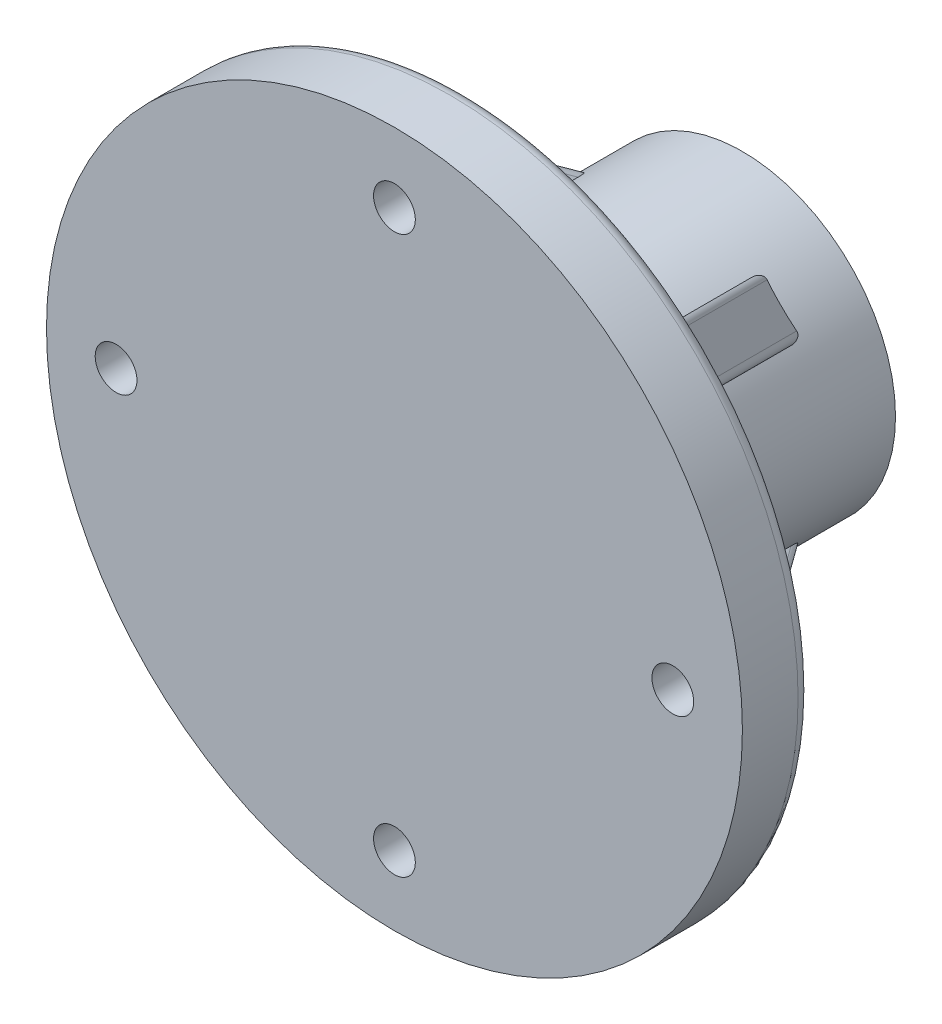
from build123d import *

# Parameters (mm, degrees)
SKETCH1_R           = 11
BOSS_EXTRUDE1_DEPTH = 20
SKETCH5_R           = 25
BOSS_EXTRUDE2_DEPTH = 5
CUT_EXTRUDE2_REACH  = 42.62
SKETCH6_R           = 1.5
FILLET2_R           = 5
RIB10_REACH         = 45.301
SKETCH12_WALL_W     = 107.81191309
SKETCH12_WALL_H     = 4
CIRPATTERN1_COUNT   = 4
FILLET3_R           = 1
FILLET4_R           = 0.5
SKETCH13_R          = 3
CUT_EXTRUDE3_DEPTH  = 1
SKETCH14_R          = 1.5
CUT_EXTRUDE4_DEPTH  = 12


with BuildPart() as part:
    # Sketch1 → Boss-Extrude1 (new body)
    with BuildSketch(Plane.XY):
        Circle(SKETCH1_R)
    extrude(amount=BOSS_EXTRUDE1_DEPTH)

    # Sketch5 → Boss-Extrude2 (add)
    with BuildSketch(Plane.XY.offset(20)):
        Circle(SKETCH5_R)
    extrude(amount=BOSS_EXTRUDE2_DEPTH)

    # Sketch6 → Cut-Extrude2 (cut, up to next)
    with BuildSketch(Plane(origin=(0, 0, 20), x_dir=(-1, 0, 0), z_dir=(0, 0, -1)), mode=Mode.PRIVATE) as cut_extrude2_sk1:
        with Locations((0, 20)):
            Circle(SKETCH6_R)
    cut_extrude2_tool1 = extrude(cut_extrude2_sk1.sketch, amount=-CUT_EXTRUDE2_REACH, mode=Mode.PRIVATE) & part.part
    # Sketch6 → Cut-Extrude2 (cut, up to next)
    with BuildSketch(Plane(origin=(0, 0, 20), x_dir=(-1, 0, 0), z_dir=(0, 0, -1)), mode=Mode.PRIVATE) as cut_extrude2_sk2:
        with Locations((0, -20)):
            Circle(SKETCH6_R)
    cut_extrude2_tool2 = extrude(cut_extrude2_sk2.sketch, amount=-CUT_EXTRUDE2_REACH, mode=Mode.PRIVATE) & part.part
    # Sketch6 → Cut-Extrude2 (cut, up to next)
    with BuildSketch(Plane(origin=(0, 0, 20), x_dir=(-1, 0, 0), z_dir=(0, 0, -1)), mode=Mode.PRIVATE) as cut_extrude2_sk3:
        with Locations((-20, 0)):
            Circle(SKETCH6_R)
    cut_extrude2_tool3 = extrude(cut_extrude2_sk3.sketch, amount=-CUT_EXTRUDE2_REACH, mode=Mode.PRIVATE) & part.part
    # Sketch6 → Cut-Extrude2 (cut, up to next)
    with BuildSketch(Plane(origin=(0, 0, 20), x_dir=(-1, 0, 0), z_dir=(0, 0, -1)), mode=Mode.PRIVATE) as cut_extrude2_sk4:
        with Locations((20, 0)):
            Circle(SKETCH6_R)
    cut_extrude2_tool4 = extrude(cut_extrude2_sk4.sketch, amount=-CUT_EXTRUDE2_REACH, mode=Mode.PRIVATE) & part.part
    add(cut_extrude2_tool1.solids().sort_by_distance((0, 20, 20))[0], mode=Mode.SUBTRACT)
    add(cut_extrude2_tool2.solids().sort_by_distance((0, -20, 20))[0], mode=Mode.SUBTRACT)
    add(cut_extrude2_tool3.solids().sort_by_distance((20, 0, 20))[0], mode=Mode.SUBTRACT)
    add(cut_extrude2_tool4.solids().sort_by_distance((-20, 0, 20))[0], mode=Mode.SUBTRACT)

    # Fillet2
    fillet2_edges = [part.edges().sort_by_distance(p)[0] for p in [
        (-11, 0, 20),
    ]]
    fillet(fillet2_edges, radius=FILLET2_R)

    # Sketch12 wall → Rib10 (add, up to next)
    with BuildSketch(Plane(origin=(12.02081528, 12.02081528, 12.5), x_dir=(0.441726104292, 0.441726104292, 0.780868809452), z_dir=(0.55215763038, 0.55215763038, -0.624695047544)), mode=Mode.PRIVATE) as rib10_sk1:
        Rectangle(SKETCH12_WALL_W, SKETCH12_WALL_H)
    rib10_tool1 = extrude(rib10_sk1.sketch, amount=-RIB10_REACH, mode=Mode.PRIVATE) - part.part
    rib10 = rib10_tool1.solids().sort_by_distance((12.02081528, 12.02081528, 12.5))[0]
    add(rib10)

    # CirPattern1: Rib10 ×4 about axis
    cirpattern1_axis = Axis((0, 0, 0), (0, 0, 1))
    for i in range(1, CIRPATTERN1_COUNT):
        add(rib10.rotate(cirpattern1_axis, i * 360 / CIRPATTERN1_COUNT))

    # Fillet3
    fillet3_edges = [part.edges().sort_by_distance(p)[0] for p in [
        (-25, 0, 20),
    ]]
    fillet(fillet3_edges, radius=FILLET3_R)

    # Fillet4
    fillet4_edges = [part.edges().sort_by_distance(p)[0] for p in [
        (10.541779056, -13.370206181, 12.385408642),
        (13.370206181, -10.541779056, 12.385408642),
        (-10.541779056, -13.370206181, 12.385408642),
        (-13.370206181, -10.541779056, 12.385408642),
        (13.370206181, 10.541779056, 12.385408642),
        (10.541779056, 13.370206181, 12.385408642),
        (-13.370206181, 10.541779056, 12.385408642),
        (-10.541779056, 13.370206181, 12.385408642),
    ]]
    fillet(fillet4_edges, radius=FILLET4_R)

    # Sketch13 → Cut-Extrude3 (cut)
    with BuildSketch(Plane(origin=(0, 0, 20), x_dir=(-1, 0, 0), z_dir=(0, 0, -1))):
        with Locations((-20, 0)):
            Circle(SKETCH13_R)
        with Locations((0, 20)):
            Circle(SKETCH13_R)
        with Locations((20, 0)):
            Circle(SKETCH13_R)
        with Locations((0, -20)):
            Circle(SKETCH13_R)
    extrude(amount=-CUT_EXTRUDE3_DEPTH, mode=Mode.SUBTRACT)

    # Sketch14 → Cut-Extrude4 (cut)
    with BuildSketch(Plane(origin=(0, 0, 0), x_dir=(-1, 0, 0), z_dir=(0, 0, -1))):
        with Locations((-5.656854249, 5.656854249)):
            Circle(SKETCH14_R)
        with Locations((5.656854249, -5.656854249)):
            Circle(SKETCH14_R)
        with Locations((5.656854249, 5.656854249)):
            Circle(SKETCH14_R)
        with Locations(Location((-5.656854249, -5.656854249, 0), (0, 0, 180))):
            Circle(SKETCH14_R)
    extrude(amount=-CUT_EXTRUDE4_DEPTH, mode=Mode.SUBTRACT)


solid = part.part
